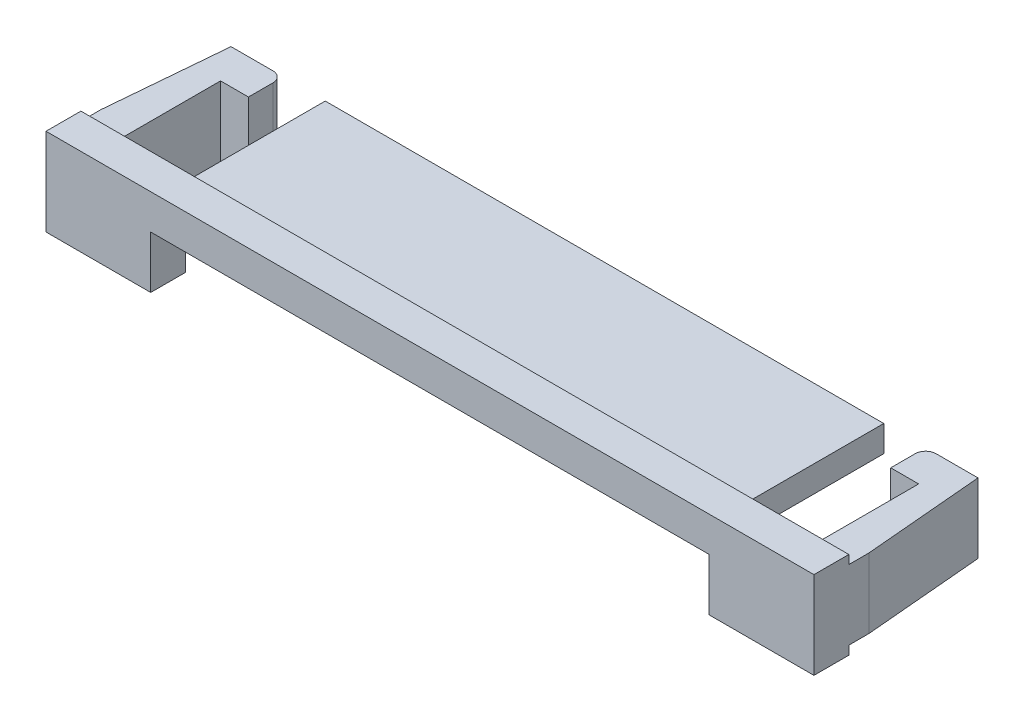
from build123d import *

# Parameters (mm, degrees)
SKETCH1_W             = 22
SKETCH1_H             = 2.5
BOSS_EXTRUDE1_DEPTH   = 5
SKETCH2_W             = 22
SKETCH2_H             = 0.25
CUT_EXTRUDE1_DEPTH    = 4
SKETCH3_W             = 2
SKETCH3_H             = 2
CUT_EXTRUDE2_DEPTH    = 4
SKETCH5_W             = 16
SKETCH5_H             = 1.5
CUT_EXTRUDE3_DEPTH    = 5
SKETCH6_W             = 1.8
SKETCH6_H             = 1
BOSS_EXTRUDE2_DEPTH   = 2
FILLET1_R             = 0.3
CHAMFER1_SIZE         = 0.3
CHAMFER1_SIZE2        = 3.429015691
CHAMFER1_PART_2_SIZE  = 0.3
CHAMFER1_PART_2_SIZE2 = 3.429015691


with BuildPart() as part:
    # Sketch1 → Boss-Extrude1 (new body)
    with BuildSketch(Plane.XY):
        Rectangle(SKETCH1_W, SKETCH1_H)
    extrude(amount=BOSS_EXTRUDE1_DEPTH)

    # Sketch2 → Cut-Extrude1 (cut)
    with BuildSketch(Plane(origin=(0, 0, 0), x_dir=(-1, 0, 0), z_dir=(0, 0, -1))):
        with Locations((0, 1.125)):
            Rectangle(SKETCH2_W, SKETCH2_H)
        with Locations((0, -1.125)):
            Rectangle(SKETCH2_W, SKETCH2_H)
    extrude(amount=-CUT_EXTRUDE1_DEPTH, mode=Mode.SUBTRACT)

    # Sketch3 → Cut-Extrude2 (cut)
    with BuildSketch(Plane(origin=(0, 0, 0), x_dir=(-1, 0, 0), z_dir=(0, 0, -1))):
        with Locations((-9, 0)):
            Rectangle(SKETCH3_W, SKETCH3_H)
        with Locations((9, 0)):
            Rectangle(SKETCH3_W, SKETCH3_H)
    extrude(amount=-CUT_EXTRUDE2_DEPTH, mode=Mode.SUBTRACT)

    # Sketch5 → Cut-Extrude3 (cut)
    with BuildSketch(Plane(origin=(0, 0, 0), x_dir=(-1, 0, 0), z_dir=(0, 0, -1))):
        with Locations((0, -0.5)):
            Rectangle(SKETCH5_W, SKETCH5_H)
    extrude(amount=-CUT_EXTRUDE3_DEPTH, mode=Mode.SUBTRACT)

    # Sketch6 → Boss-Extrude2 (add)
    with BuildSketch(Plane(origin=(0, 1, 0), x_dir=(1, 0, 0), z_dir=(0, 1, 0))):
        with Locations((-10.1, -0.5)):
            Rectangle(SKETCH6_W, SKETCH6_H)
        with Locations((10.1, -0.5)):
            Rectangle(SKETCH6_W, SKETCH6_H)
    extrude(amount=-BOSS_EXTRUDE2_DEPTH)

    # Fillet1
    fillet1_edges = [part.edges().sort_by_distance(p)[0] for p in [
        (-9.2, 0, 0),
        (9.2, 0, 0),
    ]]
    fillet(fillet1_edges, radius=FILLET1_R)

    # Chamfer1
    chamfer1_edges = [part.edges().sort_by_distance(p)[0] for p in [
        (11, 0, 0),
    ]]
    chamfer1_side = [part.faces().sort_by_distance(p)[0] for p in [
        (10.25, 0, 0),
    ]]
    chamfer(chamfer1_edges, length=CHAMFER1_SIZE, length2=CHAMFER1_SIZE2, reference=chamfer1_side[0])

    # Chamfer1 part 2
    chamfer1_part_2_edges = [part.edges().sort_by_distance(p)[0] for p in [
        (-11, 0, 0),
    ]]
    chamfer1_part_2_side = [part.faces().sort_by_distance(p)[0] for p in [
        (-10.25, 0, 0),
    ]]
    chamfer(chamfer1_part_2_edges, length=CHAMFER1_PART_2_SIZE, length2=CHAMFER1_PART_2_SIZE2, reference=chamfer1_part_2_side[0])


solid = part.part
